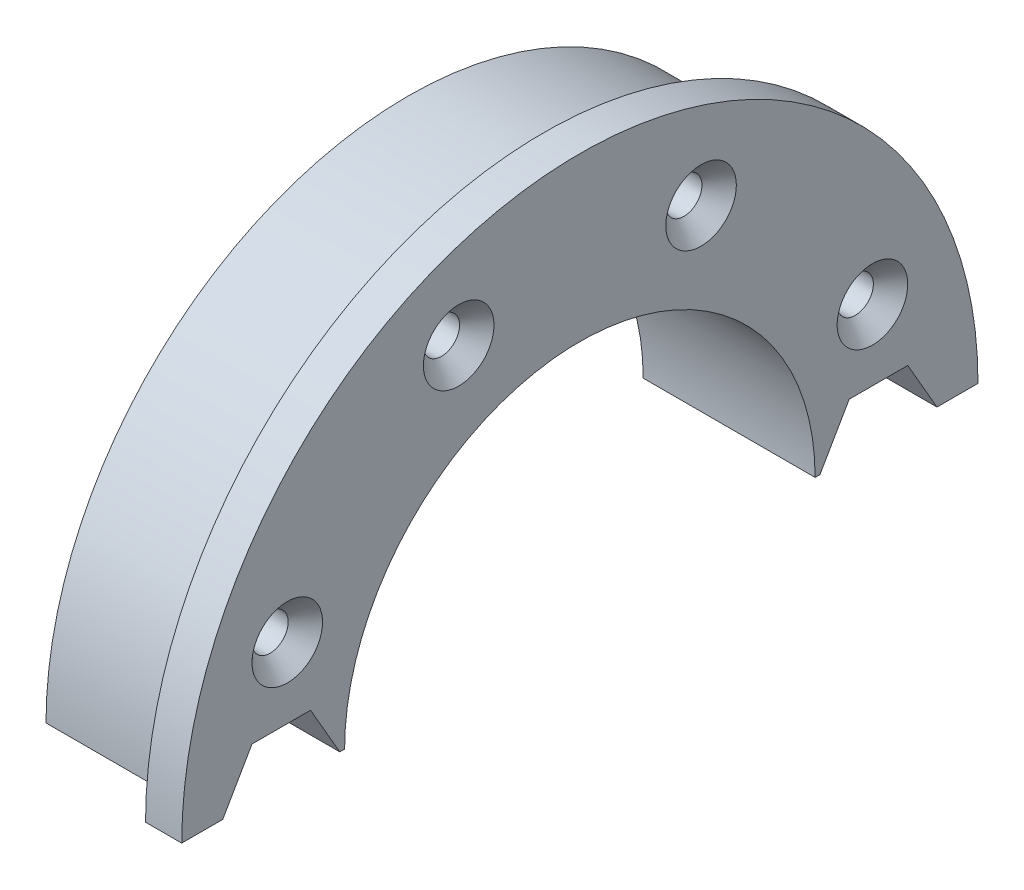
from build123d import *

# Parameters (mm, degrees)
ROTATION1_ANGLE                                      = 180
FORMSENKUNG_F_R_M3_SENKSCHRAUBE_MIT_INNE_D           = 1.6
FORMSENKUNG_F_R_M3_SENKSCHRAUBE_MIT_INNE_DEPTH       = 12
FORMSENKUNG_F_R_M3_SENKSCHRAUBE_MIT_INNE_CSINK_D     = 3.9
FORMSENKUNG_F_R_M3_SENKSCHRAUBE_MIT_INNE_CSINK_ANGLE = 90
FORMSENKUNG_F_R_M3_SENKSCHRAUBE_MIT_INNE_TIP         = 0.480688495
SKIZZE12_R                                           = 1
SCHNITT_LINEAR_AUSTRAGEN1_DEPTH                      = 33.530754679
SKIZZE9_R                                            = 3
SCHNITT_LINEAR_AUSTRAGEN2_DEPTH                      = 19
SKIZZE9_5_R                                          = 3
SCHNITT_LINEAR_AUSTRAGEN3_DEPTH                      = 16.5
SCHNITT_LINEAR_AUSTRAGEN5_DEPTH                      = 4
STIRNSENKUNG_F_R_M3_D_NNKOPF_ZYLINDERSCH_D           = 3.2
STIRNSENKUNG_F_R_M3_D_NNKOPF_ZYLINDERSCH_CBORE_D     = 5.6
STIRNSENKUNG_F_R_M3_D_NNKOPF_ZYLINDERSCH_CBORE_DEPTH = 2.1


with BuildPart() as part:
    # Skizze4 → Rotation1 (revolve, symmetric)
    with BuildSketch(Plane.XY) as rotation1_sk:
        Polygon((3.5, 20), (-4, 20), (-4, 13), (5.5, 13), (5.5, 22), (3.5, 22), align=None)
    revolve(axis=Axis((0, 0, 0), (-1, 0, 0)), revolution_arc=ROTATION1_ANGLE / 2)
    revolve(rotation1_sk.sketch, axis=Axis((0, 0, 0), (1, 0, 0)), revolution_arc=ROTATION1_ANGLE / 2)

    # Formsenkung für M3 Senkschraube mit Innensechskant1
    with Locations(Plane(origin=(5.5, 0, 0), x_dir=(0, 0, -1), z_dir=(1, 0, 0))):
        with Locations((6.696960066, 16.167891819), (-16.167891819, 6.696960066), (-6.696960066, 16.167891819), (16.167891819, 6.696960066)):
            CounterSinkHole(FORMSENKUNG_F_R_M3_SENKSCHRAUBE_MIT_INNE_D / 2, FORMSENKUNG_F_R_M3_SENKSCHRAUBE_MIT_INNE_CSINK_D / 2, depth=FORMSENKUNG_F_R_M3_SENKSCHRAUBE_MIT_INNE_DEPTH, counter_sink_angle=FORMSENKUNG_F_R_M3_SENKSCHRAUBE_MIT_INNE_CSINK_ANGLE)
            with Locations((0, 0, -(FORMSENKUNG_F_R_M3_SENKSCHRAUBE_MIT_INNE_DEPTH + FORMSENKUNG_F_R_M3_SENKSCHRAUBE_MIT_INNE_TIP / 2))):  # 118° drill point
                Cone(0, FORMSENKUNG_F_R_M3_SENKSCHRAUBE_MIT_INNE_D / 2, FORMSENKUNG_F_R_M3_SENKSCHRAUBE_MIT_INNE_TIP, mode=Mode.SUBTRACT)

    # Skizze12 → Schnitt-Linear austragen1 (cut, through all)
    with BuildSketch(Plane(origin=(5.5, 0, 0), x_dir=(0, 0, -1), z_dir=(1, 0, 0))):
        with Locations((-6.696960066, 16.167891819)):
            Circle(SKIZZE12_R)
        with Locations((6.696960066, 16.167891819)):
            Circle(SKIZZE12_R)
        with Locations((16.167891819, 6.696960066)):
            Circle(SKIZZE12_R)
        with Locations((-16.167891819, 6.696960066)):
            Circle(SKIZZE12_R)
    extrude(amount=-SCHNITT_LINEAR_AUSTRAGEN1_DEPTH, mode=Mode.SUBTRACT)

    # Skizze9 → Schnitt-Linear austragen2 (cut, symmetric)
    with BuildSketch(Plane(origin=(0, 0, 0), x_dir=(1, 0, 0), z_dir=(0, 1, 0))):
        Circle(SKIZZE9_R)
    extrude(amount=SCHNITT_LINEAR_AUSTRAGEN2_DEPTH, both=True, mode=Mode.SUBTRACT)

    # Skizze9_5 → Schnitt-Linear austragen3 (cut, symmetric)
    with BuildSketch(Plane(origin=(0, 0, 0), x_dir=(1, 0, 0), z_dir=(0, 1, 0))):
        with BuildLine():
            ThreePointArc((3.5, 0), (1.616120146, 3.104537916), (-2.007517527, 2.867032155))
            ThreePointArc((-2.007517527, 2.867032155), (-3.5, 0), (-2.007517527, -2.867032155))
            ThreePointArc((-2.007517527, -2.867032155), (1.616120146, -3.104537916), (3.5, 0))
        make_face()
        Circle(SKIZZE9_5_R, mode=Mode.SUBTRACT)
    extrude(amount=SCHNITT_LINEAR_AUSTRAGEN3_DEPTH, both=True, mode=Mode.SUBTRACT)

    # Skizze15 → Schnitt-Linear austragen5 (cut)
    with BuildSketch(Plane(origin=(5.5, 0, 0), x_dir=(0, 0, -1), z_dir=(1, 0, 0))):
        Polygon((-14.883419246, 2.8), (-18.116580754, 2.8), (-19.733161507, 0), (-18.116580754, -2.8), (-14.883419246, -2.8), (-13.266838493, 0), align=None)
        Polygon((13.266838493, 0), (14.883419246, 2.8), (18.116580754, 2.8), (19.733161507, 0), (18.116580754, -2.8), (14.883419246, -2.8), align=None)
    extrude(amount=-SCHNITT_LINEAR_AUSTRAGEN5_DEPTH, mode=Mode.SUBTRACT)

    # Stirnsenkung für M3 Dünnkopf-Zylinderschraube mit Innensechskant1 (through all)
    with Locations(Plane.ZY.offset(4)):
        with Locations((16.5, 0), (-16.5, 0)):
            CounterBoreHole(STIRNSENKUNG_F_R_M3_D_NNKOPF_ZYLINDERSCH_D / 2, STIRNSENKUNG_F_R_M3_D_NNKOPF_ZYLINDERSCH_CBORE_D / 2, STIRNSENKUNG_F_R_M3_D_NNKOPF_ZYLINDERSCH_CBORE_DEPTH)


solid = part.part
